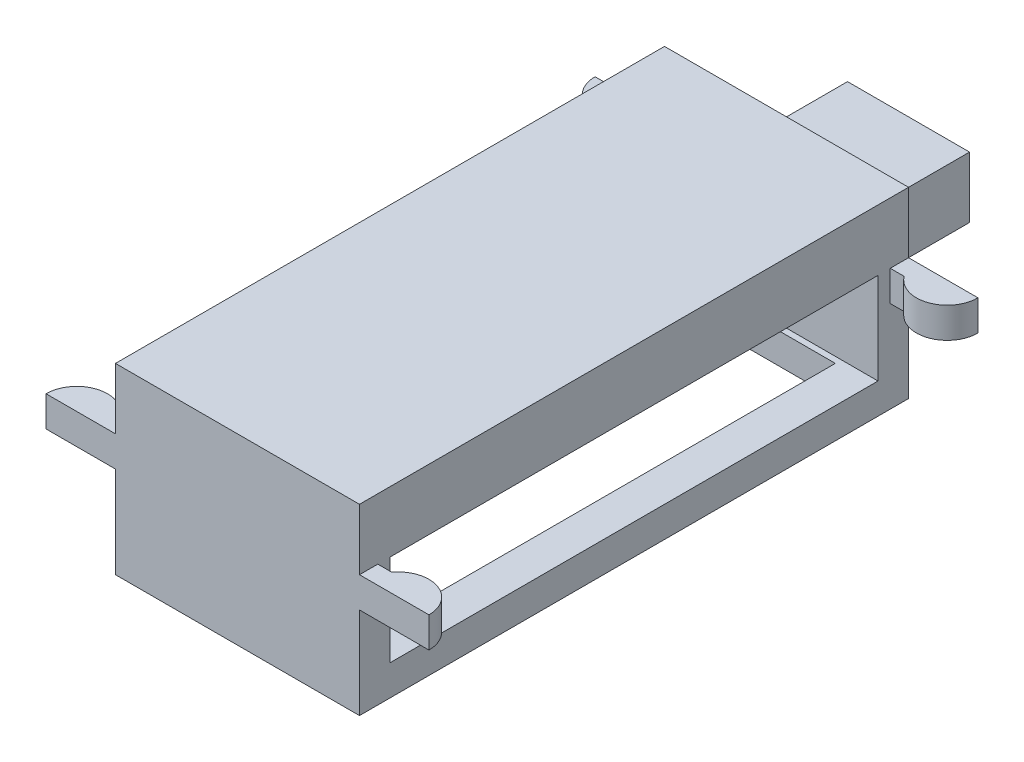
from build123d import *

# Parameters (mm, degrees)
SKETCH_1_W      = 4
SKETCH_1_H      = 8
EXTRUDE_1_DEPTH = 1
SKETCH_2_W      = 4
SKETCH_2_H      = 2.5
EXTRUDE_2_DEPTH = 0.5
SKETCH_3_W      = 4
SKETCH_3_H      = 9
SKETCH_3_W_2    = 2.8
SKETCH_3_H_2    = 7.8
EXTRUDE_3_DEPTH = 0.5
EXTRUDE_4_DEPTH = 0.5
SKETCH_5_W      = 2
SKETCH_5_H      = 1
EXTRUDE_5_DEPTH = 2


with BuildPart() as part:
    # 草图1 → 凸台-拉伸1 (new body)
    with BuildSketch(Plane(origin=(0, 0, 0), x_dir=(1, 0, 0), z_dir=(0, 1, 0))):
        Rectangle(SKETCH_1_W, SKETCH_1_H)
    extrude(amount=EXTRUDE_1_DEPTH)

    # 草图2 → 凸台-拉伸2 (add)
    with BuildSketch(Plane(origin=(0, 0, -4), x_dir=(-1, 0, 0), z_dir=(0, 0, -1))):
        with Locations((0, -0.25)):
            Rectangle(SKETCH_2_W, SKETCH_2_H)
    extrude_2 = extrude(amount=EXTRUDE_2_DEPTH)

    # 镜向1: 凸台-拉伸2 across plane
    add(extrude_2.mirror(Plane.XY))

    # 草图3 → 凸台-拉伸3 (add)
    with BuildSketch(Plane.XZ.offset(1.5)):
        Rectangle(SKETCH_3_W, SKETCH_3_H)
        Rectangle(SKETCH_3_W_2, SKETCH_3_H_2, mode=Mode.SUBTRACT)
    extrude(amount=EXTRUDE_3_DEPTH)

    # 草图4 → 凸台-拉伸4 (add)
    with BuildSketch(Plane(origin=(0, 0, 0), x_dir=(1, 0, 0), z_dir=(0, 1, 0))):
        with BuildLine():
            Line((-2, 4.5), (-3.138641266, 4.5))
            ThreePointArc((-3.138641266, 4.5), (-2.791797675, 4.020569497), (-2.227919338, 4.2))
            Line((-2.227919338, 4.2), (2.227919338, 4.2))
            ThreePointArc((2.227919338, 4.2), (2.791797675, 4.020569497), (3.138641266, 4.5))
            Line((3.138641266, 4.5), (2, 4.5))
            Line((2, 4.5), (-2, 4.5))
        make_face()
        with BuildLine():
            Line((2, -4.5), (3.138641266, -4.5))
            ThreePointArc((3.138641266, -4.5), (2.791797675, -4.020569497), (2.227919338, -4.2))
            Line((2.227919338, -4.2), (-2.227919338, -4.2))
            ThreePointArc((-2.227919338, -4.2), (-2.791797675, -4.020569497), (-3.138641266, -4.5))
            Line((-3.138641266, -4.5), (-2, -4.5))
            Line((-2, -4.5), (2, -4.5))
        make_face()
    extrude(amount=-EXTRUDE_4_DEPTH)

    # 草图5 → 凸台-拉伸5 (add)
    with BuildSketch(Plane(origin=(0, 0, -4.5), x_dir=(-1, 0, 0), z_dir=(0, 0, -1))):
        with Locations((0, -0.5)):
            Rectangle(SKETCH_5_W, SKETCH_5_H)
    extrude(amount=EXTRUDE_5_DEPTH)


solid = part.part
